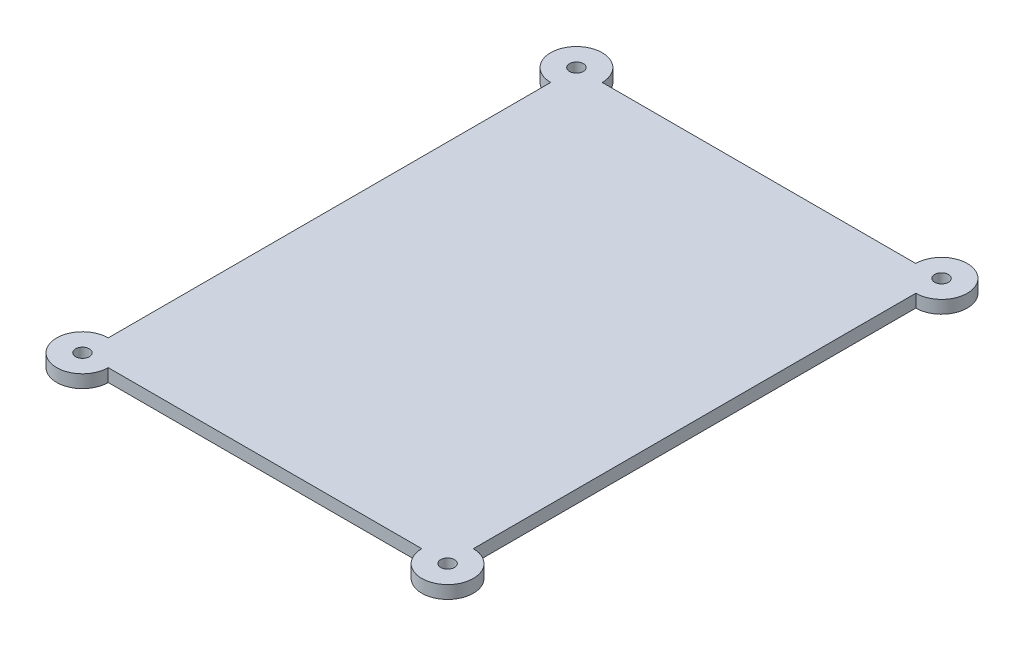
from build123d import *

# Parameters (mm, degrees)
SKETCH1_W           = 85
SKETCH1_H           = 115
BOSS_EXTRUDE1_DEPTH = 3
SKETCH2_R           = 1.6
CUT_EXTRUDE1_DEPTH  = 40


with BuildPart() as part:
    # Sketch1 → Boss-Extrude1 (new body)
    with BuildSketch(Plane(origin=(0, 0, 0), x_dir=(1, 0, 0), z_dir=(0, 1, 0))):
        Rectangle(SKETCH1_W, SKETCH1_H)
        with BuildLine():
            Line((-36.5, -57.5), (-42.5, -57.5))
            Line((-42.5, -57.5), (-42.5, -51.5))
            ThreePointArc((-42.5, -51.5), (-46.742640687, -61.742640687), (-36.5, -57.5))
        make_face()
        with BuildLine():
            Line((42.5, -57.5), (36.5, -57.5))
            ThreePointArc((36.5, -57.5), (46.742640687, -61.742640687), (42.5, -51.5))
            Line((42.5, -51.5), (42.5, -57.5))
        make_face()
        with BuildLine():
            Line((42.5, 57.5), (42.5, 51.5))
            ThreePointArc((42.5, 51.5), (46.742640687, 61.742640687), (36.5, 57.5))
            Line((36.5, 57.5), (42.5, 57.5))
        make_face()
        with BuildLine():
            ThreePointArc((-36.5, 57.5), (-46.742640687, 61.742640687), (-42.5, 51.5))
            Line((-42.5, 51.5), (-42.5, 57.5))
            Line((-42.5, 57.5), (-36.5, 57.5))
        make_face()
    extrude(amount=BOSS_EXTRUDE1_DEPTH)

    # Sketch2 → Cut-Extrude1 (cut)
    with BuildSketch(Plane.XZ):
        with Locations((-42.5, 57.5)):
            Circle(SKETCH2_R)
        with Locations((42.5, 57.5)):
            Circle(SKETCH2_R)
        with Locations((42.5, -57.5)):
            Circle(SKETCH2_R)
        with Locations((-42.5, -57.5)):
            Circle(SKETCH2_R)
    extrude(amount=-CUT_EXTRUDE1_DEPTH, mode=Mode.SUBTRACT)


solid = part.part
